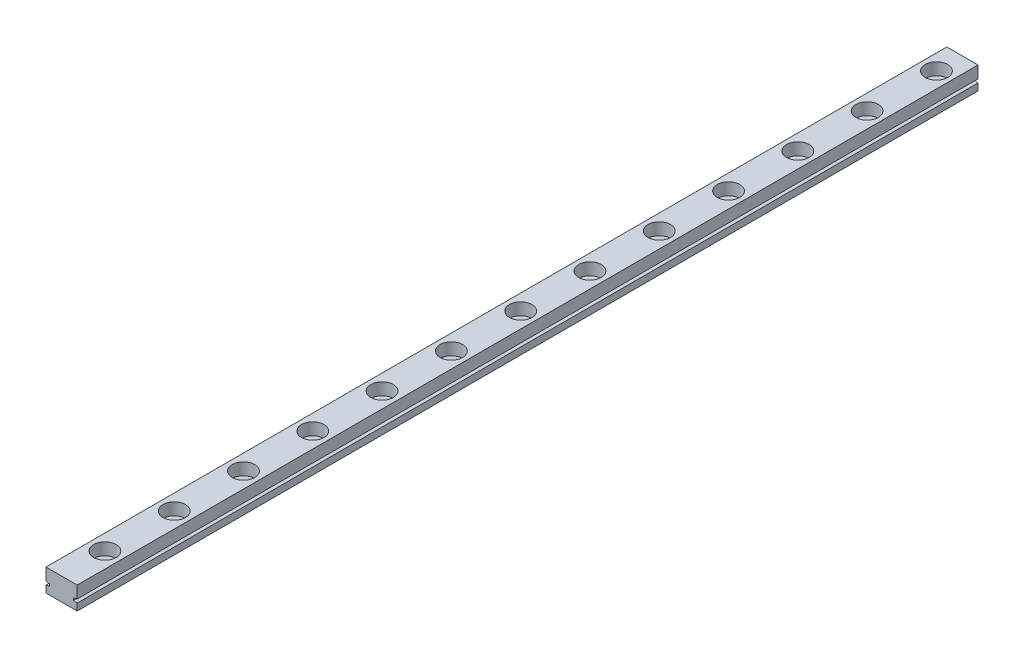
from build123d import *

# Parameters (mm, degrees)
SKETCH_1_W          = 9
SKETCH_1_H          = 6.5
EXTRUDE_1_DEPTH     = 260
SKETCH_2_R          = 1.75
CUT_EXTRUDE_1_DEPTH = 7.5
SKETCH_3_R          = 3.25
CUT_EXTRUDE_2_DEPTH = 3.5
CUT_EXTRUDE_3_DEPTH = 261


with BuildPart() as part:
    # 草图1 → 凸台-拉伸1 (new body)
    with BuildSketch(Plane.XY):
        Rectangle(SKETCH_1_W, SKETCH_1_H)
    extrude(amount=EXTRUDE_1_DEPTH)

    # 草图2 → 切除-拉伸1 (cut, through all)
    with BuildSketch(Plane(origin=(0, 3.25, 0), x_dir=(1, 0, 0), z_dir=(0, 1, 0))):
        with Locations((0, -7.5)):
            Circle(SKETCH_2_R)
        with Locations((0, -27.5)):
            Circle(SKETCH_2_R)
        with Locations((0, -47.5)):
            Circle(SKETCH_2_R)
        with Locations((0, -67.5)):
            Circle(SKETCH_2_R)
        with Locations((0, -87.5)):
            Circle(SKETCH_2_R)
        with Locations((0, -107.5)):
            Circle(SKETCH_2_R)
        with Locations((0, -127.5)):
            Circle(SKETCH_2_R)
        with Locations((0, -147.5)):
            Circle(SKETCH_2_R)
        with Locations((0, -167.5)):
            Circle(SKETCH_2_R)
        with Locations((0, -187.5)):
            Circle(SKETCH_2_R)
        with Locations((0, -207.5)):
            Circle(SKETCH_2_R)
        with Locations((0, -227.5)):
            Circle(SKETCH_2_R)
        with Locations((0, -247.5)):
            Circle(SKETCH_2_R)
        with Locations((0, -267.5)):
            Circle(SKETCH_2_R)
        with Locations((0, -287.5)):
            Circle(SKETCH_2_R)
        with Locations((0, -307.5)):
            Circle(SKETCH_2_R)
        with Locations((0, -327.5)):
            Circle(SKETCH_2_R)
        with Locations((0, -347.5)):
            Circle(SKETCH_2_R)
        with Locations((0, -367.5)):
            Circle(SKETCH_2_R)
        with Locations((0, -387.5)):
            Circle(SKETCH_2_R)
    extrude(amount=-CUT_EXTRUDE_1_DEPTH, mode=Mode.SUBTRACT)

    # 草图3 → 切除-拉伸2 (cut)
    with BuildSketch(Plane(origin=(0, 3.25, 0), x_dir=(1, 0, 0), z_dir=(0, 1, 0))):
        with Locations((0, -7.5)):
            Circle(SKETCH_3_R)
        with Locations((0, -27.5)):
            Circle(SKETCH_3_R)
        with Locations((0, -47.5)):
            Circle(SKETCH_3_R)
        with Locations((0, -67.5)):
            Circle(SKETCH_3_R)
        with Locations((0, -87.5)):
            Circle(SKETCH_3_R)
        with Locations((0, -107.5)):
            Circle(SKETCH_3_R)
        with Locations((0, -127.5)):
            Circle(SKETCH_3_R)
        with Locations((0, -147.5)):
            Circle(SKETCH_3_R)
        with Locations((0, -167.5)):
            Circle(SKETCH_3_R)
        with Locations((0, -187.5)):
            Circle(SKETCH_3_R)
        with Locations((0, -207.5)):
            Circle(SKETCH_3_R)
        with Locations((0, -227.5)):
            Circle(SKETCH_3_R)
        with Locations((0, -247.5)):
            Circle(SKETCH_3_R)
        with Locations((0, -267.5)):
            Circle(SKETCH_3_R)
        with Locations((0, -287.5)):
            Circle(SKETCH_3_R)
        with Locations((0, -307.5)):
            Circle(SKETCH_3_R)
        with Locations((0, -327.5)):
            Circle(SKETCH_3_R)
        with Locations((0, -347.5)):
            Circle(SKETCH_3_R)
        with Locations((0, -367.5)):
            Circle(SKETCH_3_R)
        with Locations((0, -387.5)):
            Circle(SKETCH_3_R)
    extrude(amount=-CUT_EXTRUDE_2_DEPTH, mode=Mode.SUBTRACT)

    # 草图4 → 切除-拉伸3 (cut, through all)
    with BuildSketch(Plane(origin=(0, 0, 0), x_dir=(-1, 0, 0), z_dir=(0, 0, -1))):
        Polygon((4.5, -0.25), (3.5, -0.45), (3.5, -1.05), (4.5, -1.25), align=None)
        Polygon((-4.5, -0.25), (-3.5, -0.45), (-3.5, -1.05), (-4.5, -1.25), align=None)
    extrude(amount=-CUT_EXTRUDE_3_DEPTH, mode=Mode.SUBTRACT)


solid = part.part
